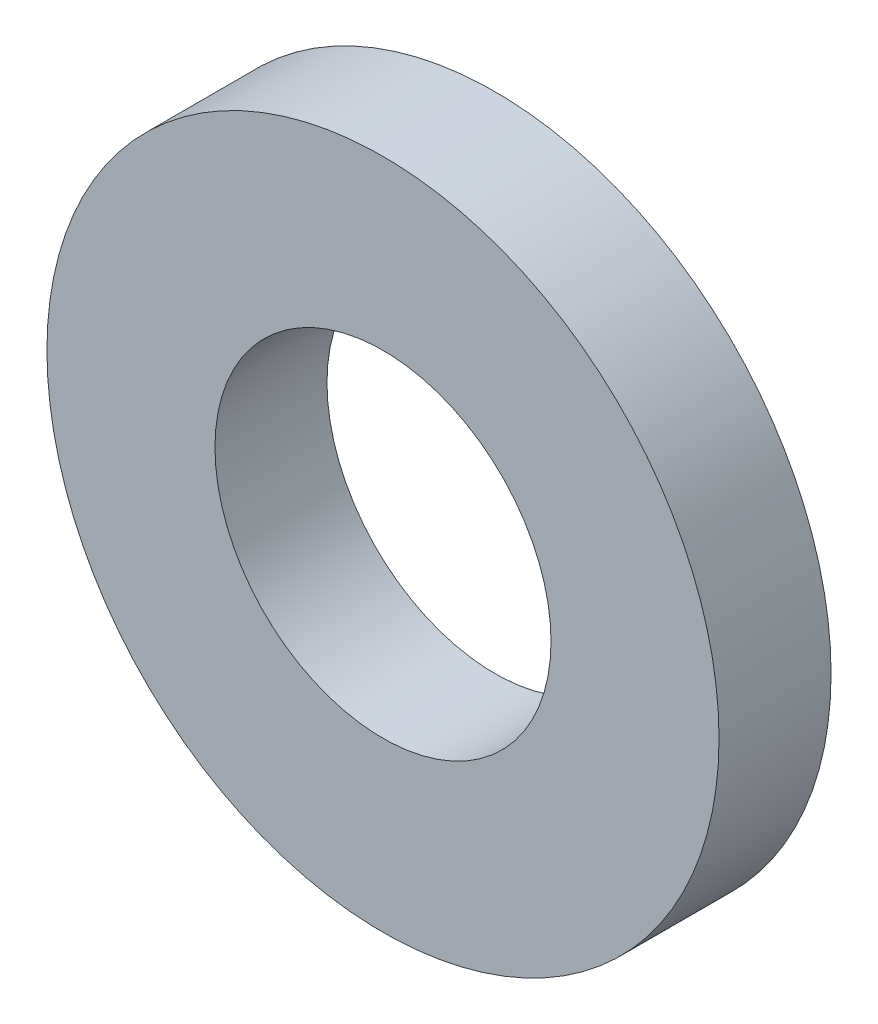
from build123d import *

# Parameters (mm, degrees)
SKETCH1_R           = 3
SKETCH1_R_2         = 1.5
BOSS_EXTRUDE1_DEPTH = 1


with BuildPart() as part:
    # Sketch1 → Boss-Extrude1 (new body)
    with BuildSketch(Plane.XY):
        Circle(SKETCH1_R)
        Circle(SKETCH1_R_2, mode=Mode.SUBTRACT)
    extrude(amount=BOSS_EXTRUDE1_DEPTH)


solid = part.part
